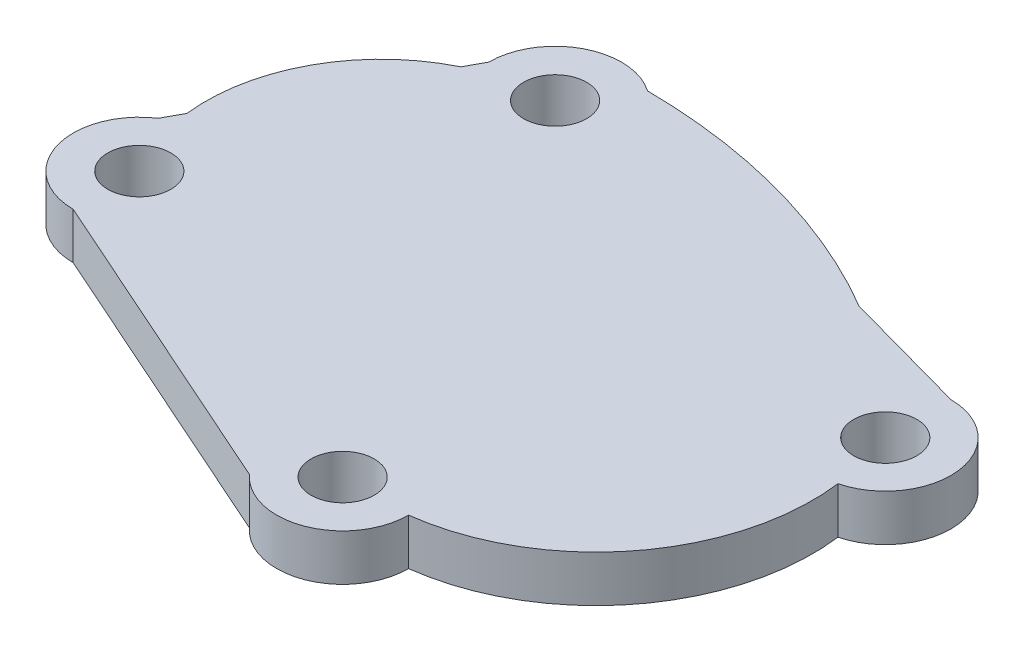
from build123d import *

# Parameters (mm, degrees)
SKETCH1_R      = 4.325
EXTRUDE1_DEPTH = 6.35


with BuildPart() as part:
    # Sketch1 → Extrude1 (new body)
    with BuildSketch(Plane(origin=(0, 0, 0), x_dir=(1, 0, 0), z_dir=(0, 1, 0))):
        with BuildLine():
            Line((0, -9.055124804), (43.550282623, -28.454685784))
            ThreePointArc((43.550282623, -28.454685784), (53.496937792, -30.809853354), (59.277793564, -22.379878865))
            ThreePointArc((59.277793564, -22.379878865), (78.989447237, -11.124841627), (84.969178064, 10.771915509))
            ThreePointArc((84.969178064, 10.771915509), (91.664608112, 20.616056931), (82.735296136, 28.490273813))
            Line((82.735296136, 28.490273813), (65.366646785, 33.285339694))
            ThreePointArc((65.366646785, 33.285339694), (46.065339232, 41.463051172), (25.302313168, 44.34613753))
            ThreePointArc((25.302313168, 44.34613753), (15.889627698, 44.942765056), (11.002555987, 36.876096458))
            Line((11.002555987, 36.876096458), (9.659067514, 34.411727615))
            ThreePointArc((9.659067514, 34.411727615), (-0.818805509, 24.364317263), (-3.587222868, 10.113978909))
            Line((-3.587222868, 10.113978909), (-4.976998188, 7.564705828))
            ThreePointArc((-4.976998188, 7.564705828), (-8.67452133, -2.597684531), (0, -9.055124804))
        make_face()
        with Locations(Location((20.103569583, 36.876096458, 0), (0, 0, 270))):  # turned: the seam where the file's is
            Circle(SKETCH1_R, mode=Mode.SUBTRACT)
        with Locations(Location((0, 0, 0), (0, 0, 270))):  # turned: the seam where the file's is
            Circle(SKETCH1_R, mode=Mode.SUBTRACT)
        with Locations(Location((50.240830228, -22.379878865, 0), (0, 0, 270))):  # turned: the seam where the file's is
            Circle(SKETCH1_R, mode=Mode.SUBTRACT)
        with Locations(Location((82.735296136, 19.490273813, 0), (0, 0, 270))):  # turned: the seam where the file's is
            Circle(SKETCH1_R, mode=Mode.SUBTRACT)
    extrude(amount=EXTRUDE1_DEPTH)


solid = part.part
